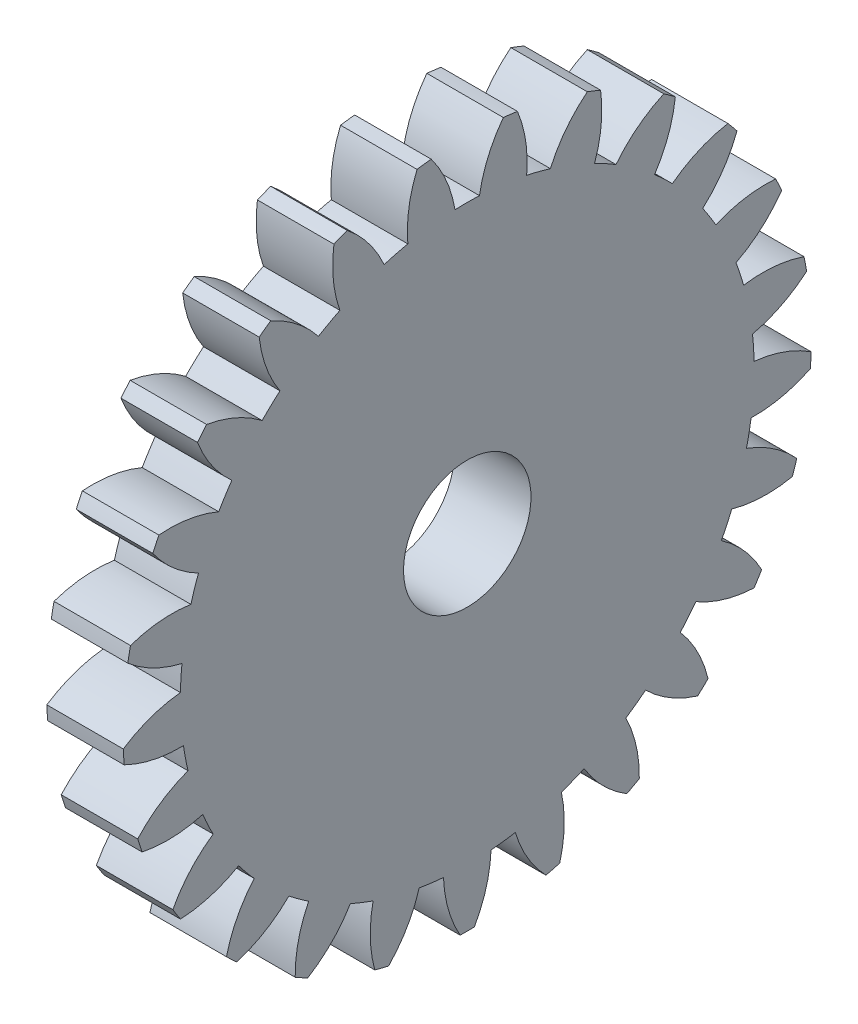
from build123d import *

# Parameters (mm, degrees)
BASPROSKE_W     = 3
BASPROSKE_H     = 13.5
TOOTHCUT_DEPTH  = 20.32614809
TEETHCUTS_COUNT = 25
TEETHCUTS_ANGLE = 345.6
BORSKE_R        = 2.5
BORE_DEPTH      = 50.0000508


with BuildPart() as part:
    # BasProSke → Base-Revolve (revolve)
    with BuildSketch(Plane(origin=(0, 0, 0), x_dir=(1, 0, 0), z_dir=(0, 1, 0)), mode=Mode.PRIVATE) as base_revolve_sk:
        with Locations((1.5, 6.75)):
            Rectangle(BASPROSKE_W, BASPROSKE_H)
    revolve(base_revolve_sk.sketch.rotate(Axis((-10, 0, 0), (1, 0, 0)), 180), axis=Axis((-10, 0, 0), (1, 0, 0)))

    # TooCutSke → ToothCut (cut, through all)
    with BuildSketch(Plane(origin=(0, 0, 0), x_dir=(0, 0, -1), z_dir=(1, 0, 0))):
        with BuildLine():
            ThreePointArc((0.480087995, 11.238750665), (0, 11.249), (-0.480087995, 11.238750665))
            ThreePointArc((-0.480087995, 11.238750665), (-0.821124963, 12.40220054), (-1.432168974, 13.449361962))
            ThreePointArc((-1.432168974, 13.449361962), (0, 13.5254), (1.432168974, 13.449361962))
            ThreePointArc((1.432168974, 13.449361962), (0.821124963, 12.40220054), (0.480087995, 11.238750665))
        make_face()
    toothcut = extrude(amount=TOOTHCUT_DEPTH, mode=Mode.SUBTRACT)

    # TeethCuts: ToothCut ×25 about axis
    teethcuts_axis = Axis((-10, 0, 0), (1, 0, 0))
    for i in range(1, TEETHCUTS_COUNT):
        add(toothcut.rotate(teethcuts_axis, i * TEETHCUTS_ANGLE / (TEETHCUTS_COUNT - 1)), mode=Mode.SUBTRACT)

    # BorSke → Bore (cut, symmetric)
    with BuildSketch(Plane(origin=(0, 0, 0), x_dir=(0, 0, -1), z_dir=(1, 0, 0))):
        with Locations(Location((0, 0, 0), (0, 0, 180))):
            Circle(BORSKE_R)
    extrude(amount=BORE_DEPTH, both=True, mode=Mode.SUBTRACT)


solid = part.part
